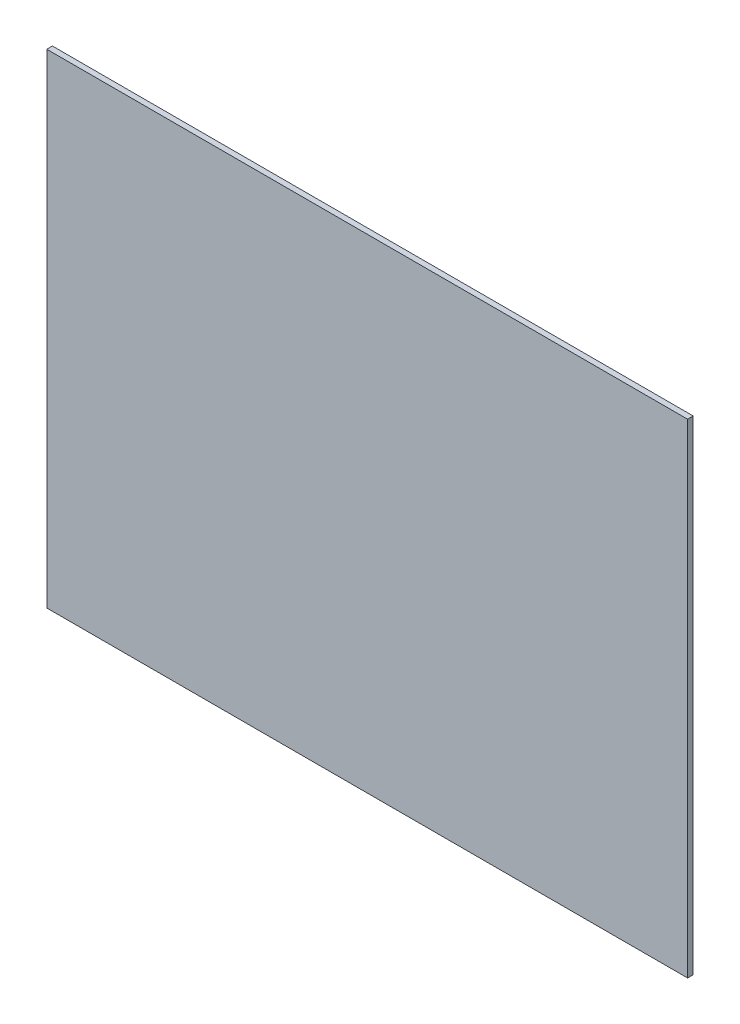
from build123d import *

# Parameters (mm, degrees)
SKETCH1_W           = 609.6
SKETCH1_H           = 460.375
BOSS_EXTRUDE1_DEPTH = 5.334


with BuildPart() as part:
    # Sketch1 → Boss-Extrude1 (new body)
    with BuildSketch(Plane.XY):
        Rectangle(SKETCH1_W, SKETCH1_H)
    extrude(amount=BOSS_EXTRUDE1_DEPTH)


solid = part.part
